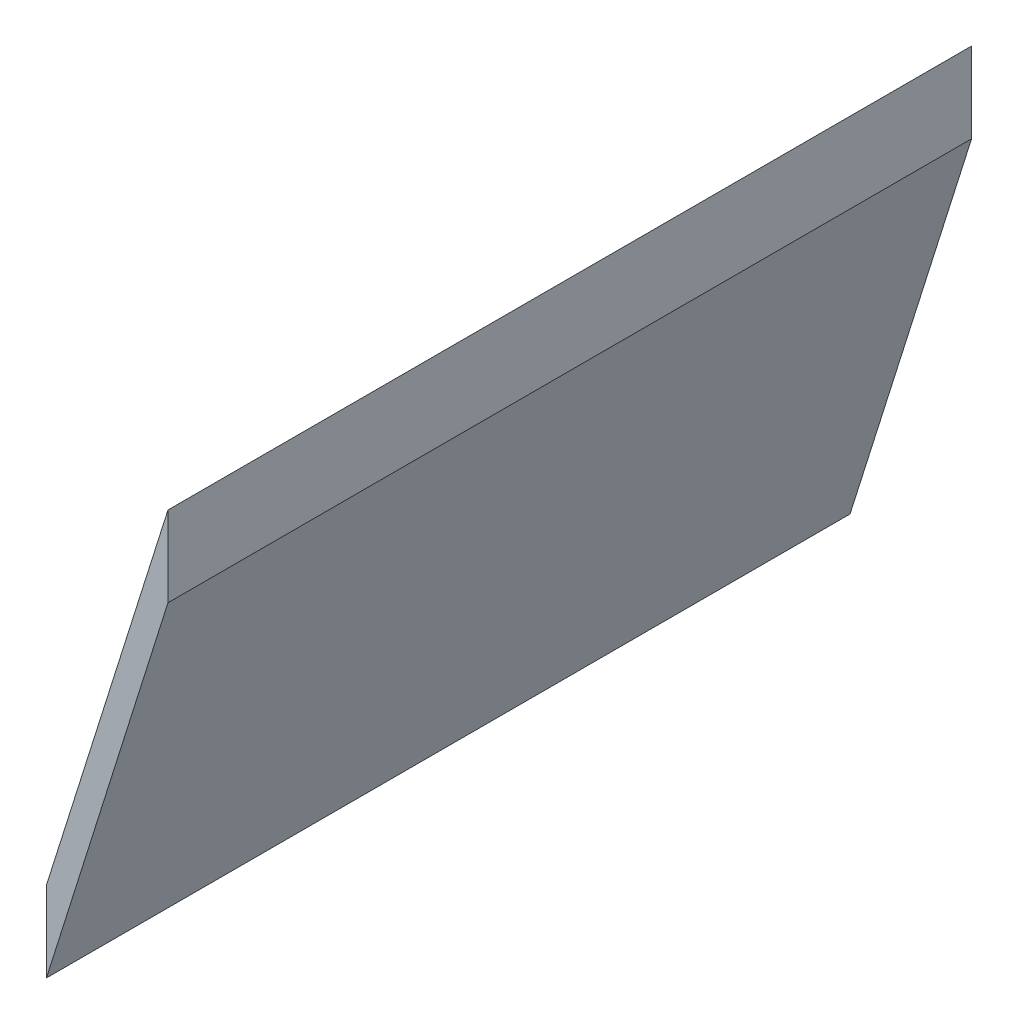
from build123d import *

# Parameters (mm, degrees)
BOSS_EXTRUDE1_DEPTH = 50


with BuildPart() as part:
    # Sketch1 → Boss-Extrude1 (new body, symmetric)
    with BuildSketch(Plane.XY):
        Polygon((15.84308786, 44.949484432), (15.84308786, 34.949484432), (0.71795591, -13.050515568), (0.71795591, -3.050515568), align=None)
    extrude(amount=BOSS_EXTRUDE1_DEPTH, both=True)


solid = part.part
